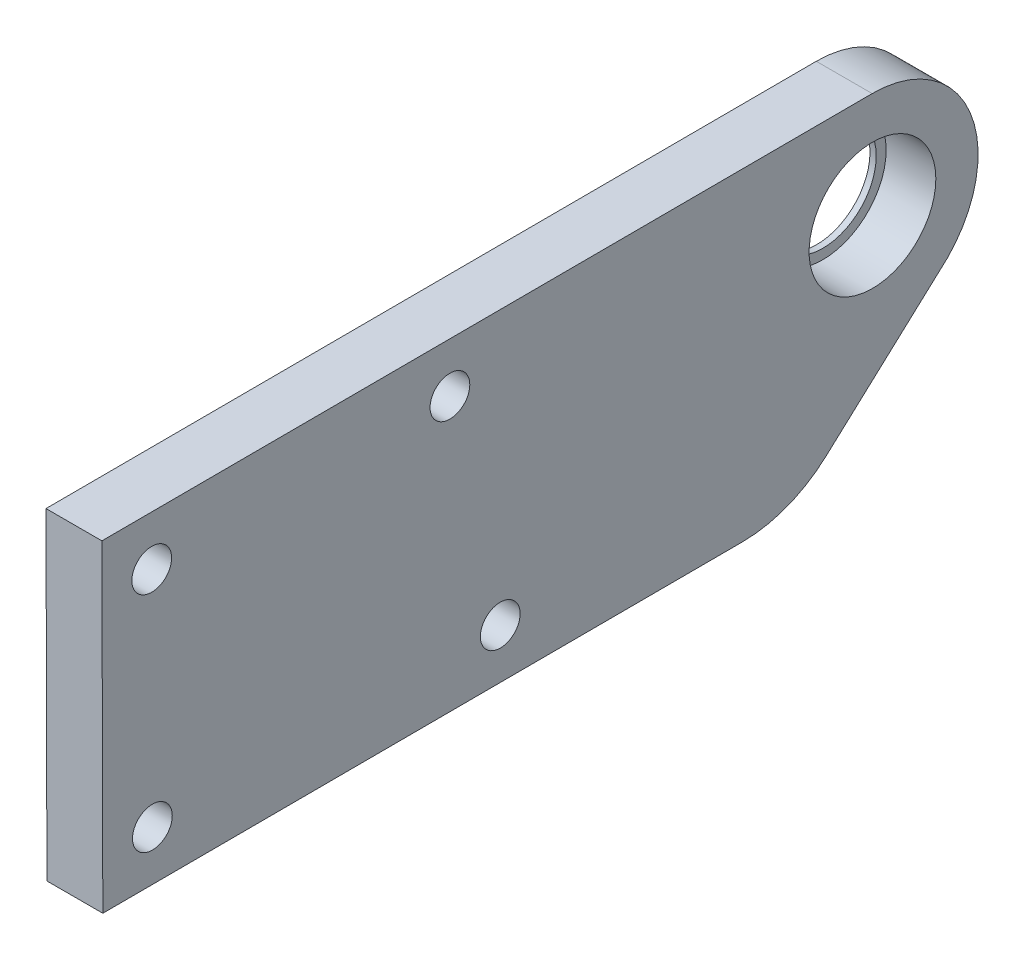
from build123d import *

# Parameters (mm, degrees)
SKETCH_1_R          = 4.3
SKETCH_1_R_2        = 1.6
EXTRUDE_1_DEPTH     = 4.5
SKETCH_2_R          = 5.1
CUT_EXTRUDE_1_DEPTH = 4


with BuildPart() as part:
    # 草图1 → 凸台-拉伸1 (new body)
    with BuildSketch(Plane(origin=(0, 0, 0), x_dir=(0, 0, -1), z_dir=(1, 0, 0))):
        with BuildLine():
            Line((-61.910667188, -17.784854846), (-10.410879829, -17.636861799))
            ThreePointArc((-10.410879829, -17.636861799), (-6.80853031, -16.954371319), (-3.69429735, -15.01936011))
            Line((-3.69429735, -15.01936011), (6.053738335, -6.112622142))
            ThreePointArc((6.053738335, -6.112622142), (7.885847556, 3.160295303), (0.014361881, 8.393204188))
            Line((0.014361881, 8.393204188), (-61.985382125, 8.215037801))
            Line((-61.985382125, 8.215037801), (-61.910667188, -17.784854846))
        make_face()
        with Locations((0.038787918, -0.106760716)):
            Circle(SKETCH_1_R, mode=Mode.SUBTRACT)
        with Locations((-57.973904035, 4.226548923)):
            Circle(SKETCH_1_R_2, mode=Mode.SUBTRACT)
        with Locations((-29.92229392, -13.692914517)):
            Circle(SKETCH_1_R_2, mode=Mode.SUBTRACT)
        with Locations((-33.97400313, 4.295516556)):
            Circle(SKETCH_1_R_2, mode=Mode.SUBTRACT)
        with Locations((-57.92217831, -13.773376756)):
            Circle(SKETCH_1_R_2, mode=Mode.SUBTRACT)
    extrude(amount=EXTRUDE_1_DEPTH)

    # 草图2 → 切除-拉伸1 (cut)
    with BuildSketch(Plane(origin=(4.5, 0, 0), x_dir=(0, 0, -1), z_dir=(1, 0, 0))):
        with Locations((0.038787918, -0.106760716)):
            Circle(SKETCH_2_R)
    extrude(amount=-CUT_EXTRUDE_1_DEPTH, mode=Mode.SUBTRACT)


solid = part.part
